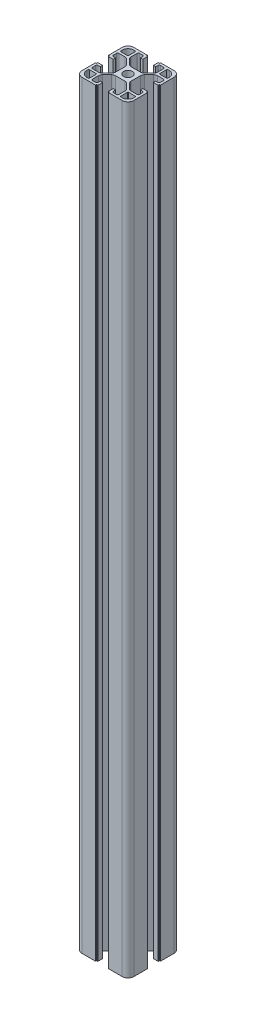
from build123d import *

# Parameters (mm, degrees)
BOSS_EXTRUDE1_DEPTH = 586


with BuildPart() as part:
    # Sketch1 → Boss-Extrude1 (new body)
    with BuildSketch(Plane(origin=(0, 0, 0), x_dir=(1, 0, 0), z_dir=(0, 1, 0))):
        with BuildLine():
            Line((84.170223908, 31.720417041), (84.170223908, 42.120417041))
            Line((84.170223908, 42.120417041), (83.570223908, 42.120417041))
            ThreePointArc((83.570223908, 42.120417041), (83.428802552, 42.178995685), (83.370223908, 42.320417041))
            Line((83.370223908, 42.320417041), (83.370223908, 42.920417041))
            ThreePointArc((83.370223908, 42.920417041), (83.311645264, 43.061838398), (83.170223908, 43.120417041))
            Line((83.170223908, 43.120417041), (79.670223908, 43.120417041))
            Line((79.670223908, 43.120417041), (79.670223908, 41.320417041))
            Line((79.670223908, 41.320417041), (81.370223908, 41.320417041))
            ThreePointArc((81.370223908, 41.320417041), (82.077330689, 41.027523823), (82.370223908, 40.320417041))
            Line((82.370223908, 40.320417041), (82.370223908, 37.970417041))
            ThreePointArc((82.370223908, 37.970417041), (82.077330689, 37.26331026), (81.370223908, 36.970417041))
            Line((81.370223908, 36.970417041), (76.723524767, 36.970417041))
            ThreePointArc((76.723524767, 36.970417041), (75.57547447, 37.198778444), (74.602204423, 37.849096698))
            Line((74.602204423, 37.849096698), (71.048903564, 41.402397557))
            ThreePointArc((71.048903564, 41.402397557), (70.39858531, 42.375667603), (70.170223908, 43.5237179))
            Line((70.170223908, 43.5237179), (70.170223908, 50.917116183))
            ThreePointArc((70.170223908, 50.917116183), (70.39858531, 52.06516648), (71.048903564, 53.038436526))
            Line((71.048903564, 53.038436526), (74.602204423, 56.591737385))
            ThreePointArc((74.602204423, 56.591737385), (75.57547447, 57.242055639), (76.723524767, 57.470417041))
            Line((76.723524767, 57.470417041), (81.370223908, 57.470417041))
            ThreePointArc((81.370223908, 57.470417041), (82.077330689, 57.177523823), (82.370223908, 56.470417041))
            Line((82.370223908, 56.470417041), (82.370223908, 54.120417041))
            ThreePointArc((82.370223908, 54.120417041), (82.077330689, 53.41331026), (81.370223908, 53.120417041))
            Line((81.370223908, 53.120417041), (79.670223908, 53.120417041))
            Line((79.670223908, 53.120417041), (79.670223908, 51.320417041))
            Line((79.670223908, 51.320417041), (83.170223908, 51.320417041))
            ThreePointArc((83.170223908, 51.320417041), (83.311645264, 51.378995685), (83.370223908, 51.520417041))
            Line((83.370223908, 51.520417041), (83.370223908, 52.120417041))
            ThreePointArc((83.370223908, 52.120417041), (83.428802552, 52.261838398), (83.570223908, 52.320417041))
            Line((83.570223908, 52.320417041), (84.170223908, 52.320417041))
            Line((84.170223908, 52.320417041), (84.170223908, 62.720417041))
            ThreePointArc((84.170223908, 62.720417041), (82.852204423, 65.902397557), (79.670223908, 67.220417041))
            Line((79.670223908, 67.220417041), (69.270223908, 67.220417041))
            Line((69.270223908, 67.220417041), (69.270223908, 66.420417041))
            Line((69.270223908, 66.420417041), (68.470223908, 66.420417041))
            ThreePointArc((68.470223908, 66.420417041), (68.328802552, 66.361838398), (68.270223908, 66.220417041))
            Line((68.270223908, 66.220417041), (68.270223908, 62.720417041))
            Line((68.270223908, 62.720417041), (70.070223908, 62.720417041))
            Line((70.070223908, 62.720417041), (70.070223908, 64.420417041))
            ThreePointArc((70.070223908, 64.420417041), (70.363117127, 65.127523823), (71.070223908, 65.420417041))
            Line((71.070223908, 65.420417041), (73.420223908, 65.420417041))
            ThreePointArc((73.420223908, 65.420417041), (74.127330689, 65.127523823), (74.420223908, 64.420417041))
            Line((74.420223908, 64.420417041), (74.420223908, 59.7737179))
            ThreePointArc((74.420223908, 59.7737179), (74.191862505, 58.625667603), (73.541544251, 57.652397557))
            Line((73.541544251, 57.652397557), (69.988243393, 54.099096698))
            ThreePointArc((69.988243393, 54.099096698), (69.014973346, 53.448778444), (67.866923049, 53.220417041))
            Line((67.866923049, 53.220417041), (60.473524767, 53.220417041))
            ThreePointArc((60.473524767, 53.220417041), (59.32547447, 53.448778444), (58.352204423, 54.099096698))
            Line((58.352204423, 54.099096698), (54.798903564, 57.652397557))
            ThreePointArc((54.798903564, 57.652397557), (54.14858531, 58.625667603), (53.920223908, 59.7737179))
            Line((53.920223908, 59.7737179), (53.920223908, 64.420417041))
            ThreePointArc((53.920223908, 64.420417041), (54.213117127, 65.127523823), (54.920223908, 65.420417041))
            Line((54.920223908, 65.420417041), (57.270223908, 65.420417041))
            ThreePointArc((57.270223908, 65.420417041), (57.977330689, 65.127523823), (58.270223908, 64.420417041))
            Line((58.270223908, 64.420417041), (58.270223908, 62.720417041))
            Line((58.270223908, 62.720417041), (60.070223908, 62.720417041))
            Line((60.070223908, 62.720417041), (60.070223908, 66.420417041))
            Line((60.070223908, 66.420417041), (59.270223908, 66.420417041))
            ThreePointArc((59.270223908, 66.420417041), (59.128802552, 66.478995685), (59.070223908, 66.620417041))
            Line((59.070223908, 66.620417041), (59.070223908, 67.220417041))
            Line((59.070223908, 67.220417041), (48.670223908, 67.220417041))
            ThreePointArc((48.670223908, 67.220417041), (45.488243393, 65.902397557), (44.170223908, 62.720417041))
            Line((44.170223908, 62.720417041), (44.170223908, 52.320417041))
            Line((44.170223908, 52.320417041), (44.770223908, 52.320417041))
            ThreePointArc((44.770223908, 52.320417041), (44.911645264, 52.261838398), (44.970223908, 52.120417041))
            Line((44.970223908, 52.120417041), (44.970223908, 51.520417041))
            ThreePointArc((44.970223908, 51.520417041), (45.028802552, 51.378995685), (45.170223908, 51.320417041))
            Line((45.170223908, 51.320417041), (48.670223908, 51.320417041))
            Line((48.670223908, 51.320417041), (48.670223908, 53.120417041))
            Line((48.670223908, 53.120417041), (46.970223908, 53.120417041))
            ThreePointArc((46.970223908, 53.120417041), (46.263117127, 53.41331026), (45.970223908, 54.120417041))
            Line((45.970223908, 54.120417041), (45.970223908, 56.470417041))
            ThreePointArc((45.970223908, 56.470417041), (46.263117127, 57.177523823), (46.970223908, 57.470417041))
            Line((46.970223908, 57.470417041), (51.616923049, 57.470417041))
            ThreePointArc((51.616923049, 57.470417041), (52.764973346, 57.242055639), (53.738243393, 56.591737385))
            Line((53.738243393, 56.591737385), (57.291544251, 53.038436526))
            ThreePointArc((57.291544251, 53.038436526), (57.941862505, 52.06516648), (58.170223908, 50.917116183))
            Line((58.170223908, 50.917116183), (58.170223908, 43.5237179))
            ThreePointArc((58.170223908, 43.5237179), (57.941862505, 42.375667603), (57.291544251, 41.402397557))
            Line((57.291544251, 41.402397557), (53.738243393, 37.849096698))
            ThreePointArc((53.738243393, 37.849096698), (52.764973346, 37.198778444), (51.616923049, 36.970417041))
            Line((51.616923049, 36.970417041), (46.970223908, 36.970417041))
            ThreePointArc((46.970223908, 36.970417041), (46.263117127, 37.26331026), (45.970223908, 37.970417041))
            Line((45.970223908, 37.970417041), (45.970223908, 40.320417041))
            ThreePointArc((45.970223908, 40.320417041), (46.263117127, 41.027523823), (46.970223908, 41.320417041))
            Line((46.970223908, 41.320417041), (48.670223908, 41.320417041))
            Line((48.670223908, 41.320417041), (48.670223908, 43.120417041))
            Line((48.670223908, 43.120417041), (45.170223908, 43.120417041))
            ThreePointArc((45.170223908, 43.120417041), (45.028802552, 43.061838398), (44.970223908, 42.920417041))
            Line((44.970223908, 42.920417041), (44.970223908, 42.320417041))
            ThreePointArc((44.970223908, 42.320417041), (44.911645264, 42.178995685), (44.770223908, 42.120417041))
            Line((44.770223908, 42.120417041), (44.170223908, 42.120417041))
            Line((44.170223908, 42.120417041), (44.170223908, 31.720417041))
            ThreePointArc((44.170223908, 31.720417041), (45.488243393, 28.538436526), (48.670223908, 27.220417041))
            Line((48.670223908, 27.220417041), (59.070223908, 27.220417041))
            Line((59.070223908, 27.220417041), (59.070223908, 27.820417041))
            ThreePointArc((59.070223908, 27.820417041), (59.128802552, 27.961838398), (59.270223908, 28.020417041))
            Line((59.270223908, 28.020417041), (59.870223908, 28.020417041))
            ThreePointArc((59.870223908, 28.020417041), (60.011645264, 28.078995685), (60.070223908, 28.220417041))
            Line((60.070223908, 28.220417041), (60.070223908, 31.720417041))
            Line((60.070223908, 31.720417041), (58.270223908, 31.720417041))
            Line((58.270223908, 31.720417041), (58.270223908, 30.020417041))
            ThreePointArc((58.270223908, 30.020417041), (57.977330689, 29.31331026), (57.270223908, 29.020417041))
            Line((57.270223908, 29.020417041), (54.920223908, 29.020417041))
            ThreePointArc((54.920223908, 29.020417041), (54.213117127, 29.31331026), (53.920223908, 30.020417041))
            Line((53.920223908, 30.020417041), (53.920223908, 34.667116183))
            ThreePointArc((53.920223908, 34.667116183), (54.14858531, 35.81516648), (54.798903564, 36.788436526))
            Line((54.798903564, 36.788436526), (58.352204423, 40.341737385))
            ThreePointArc((58.352204423, 40.341737385), (59.32547447, 40.992055639), (60.473524767, 41.220417041))
            Line((60.473524767, 41.220417041), (67.866923049, 41.220417041))
            ThreePointArc((67.866923049, 41.220417041), (69.014973346, 40.992055639), (69.988243393, 40.341737385))
            Line((69.988243393, 40.341737385), (73.541544251, 36.788436526))
            ThreePointArc((73.541544251, 36.788436526), (74.191862505, 35.81516648), (74.420223908, 34.667116183))
            Line((74.420223908, 34.667116183), (74.420223908, 30.020417041))
            ThreePointArc((74.420223908, 30.020417041), (74.127330689, 29.31331026), (73.420223908, 29.020417041))
            Line((73.420223908, 29.020417041), (71.070223908, 29.020417041))
            ThreePointArc((71.070223908, 29.020417041), (70.363117127, 29.31331026), (70.070223908, 30.020417041))
            Line((70.070223908, 30.020417041), (70.070223908, 31.720417041))
            Line((70.070223908, 31.720417041), (68.270223908, 31.720417041))
            Line((68.270223908, 31.720417041), (68.270223908, 28.220417041))
            ThreePointArc((68.270223908, 28.220417041), (68.328802552, 28.078995685), (68.470223908, 28.020417041))
            Line((68.470223908, 28.020417041), (69.070223908, 28.020417041))
            ThreePointArc((69.070223908, 28.020417041), (69.211645264, 27.961838398), (69.270223908, 27.820417041))
            Line((69.270223908, 27.820417041), (69.270223908, 27.220417041))
            Line((69.270223908, 27.220417041), (79.670223908, 27.220417041))
            ThreePointArc((79.670223908, 27.220417041), (82.852204423, 28.538436526), (84.170223908, 31.720417041))
        make_face()
        with BuildLine():
            Line((82.370223908, 34.670417041), (82.370223908, 33.520417041))
            ThreePointArc((82.370223908, 33.520417041), (81.052204423, 30.338436526), (77.870223908, 29.020417041))
            Line((77.870223908, 29.020417041), (76.720223908, 29.020417041))
            ThreePointArc((76.720223908, 29.020417041), (76.366670517, 29.166863651), (76.220223908, 29.520417041))
            Line((76.220223908, 29.520417041), (76.220223908, 34.670417041))
            ThreePointArc((76.220223908, 34.670417041), (76.366670517, 35.023970432), (76.720223908, 35.170417041))
            Line((76.720223908, 35.170417041), (81.870223908, 35.170417041))
            ThreePointArc((81.870223908, 35.170417041), (82.223777298, 35.023970432), (82.370223908, 34.670417041))
        make_face(mode=Mode.SUBTRACT)
        with BuildLine():
            Line((51.620223908, 29.020417041), (50.470223908, 29.020417041))
            ThreePointArc((50.470223908, 29.020417041), (47.288243393, 30.338436526), (45.970223908, 33.520417041))
            Line((45.970223908, 33.520417041), (45.970223908, 34.670417041))
            ThreePointArc((45.970223908, 34.670417041), (46.116670517, 35.023970432), (46.470223908, 35.170417041))
            Line((46.470223908, 35.170417041), (51.620223908, 35.170417041))
            ThreePointArc((51.620223908, 35.170417041), (51.973777298, 35.023970432), (52.120223908, 34.670417041))
            Line((52.120223908, 34.670417041), (52.120223908, 29.520417041))
            ThreePointArc((52.120223908, 29.520417041), (51.973777298, 29.166863651), (51.620223908, 29.020417041))
        make_face(mode=Mode.SUBTRACT)
        with BuildLine():
            Line((45.970223908, 59.770417041), (45.970223908, 60.920417041))
            ThreePointArc((45.970223908, 60.920417041), (47.288243393, 64.102397557), (50.470223908, 65.420417041))
            Line((50.470223908, 65.420417041), (51.620223908, 65.420417041))
            ThreePointArc((51.620223908, 65.420417041), (51.973777298, 65.273970432), (52.120223908, 64.920417041))
            Line((52.120223908, 64.920417041), (52.120223908, 59.770417041))
            ThreePointArc((52.120223908, 59.770417041), (51.973777298, 59.416863651), (51.620223908, 59.270417041))
            Line((51.620223908, 59.270417041), (46.470223908, 59.270417041))
            ThreePointArc((46.470223908, 59.270417041), (46.116670517, 59.416863651), (45.970223908, 59.770417041))
        make_face(mode=Mode.SUBTRACT)
        with BuildLine():
            Line((76.720223908, 65.420417041), (77.870223908, 65.420417041))
            ThreePointArc((77.870223908, 65.420417041), (81.052204423, 64.102397557), (82.370223908, 60.920417041))
            Line((82.370223908, 60.920417041), (82.370223908, 59.770417041))
            ThreePointArc((82.370223908, 59.770417041), (82.223777298, 59.416863651), (81.870223908, 59.270417041))
            Line((81.870223908, 59.270417041), (76.720223908, 59.270417041))
            ThreePointArc((76.720223908, 59.270417041), (76.366670517, 59.416863651), (76.220223908, 59.770417041))
            Line((76.220223908, 59.770417041), (76.220223908, 64.920417041))
            ThreePointArc((76.220223908, 64.920417041), (76.366670517, 65.273970432), (76.720223908, 65.420417041))
        make_face(mode=Mode.SUBTRACT)
        with BuildLine():
            ThreePointArc((60.770223908, 47.220417041), (64.170223908, 43.820417041), (67.570223908, 47.220417041))
            ThreePointArc((67.570223908, 47.220417041), (64.170223908, 50.620417041), (60.770223908, 47.220417041))
        make_face(mode=Mode.SUBTRACT)
    extrude(amount=BOSS_EXTRUDE1_DEPTH)


solid = part.part
